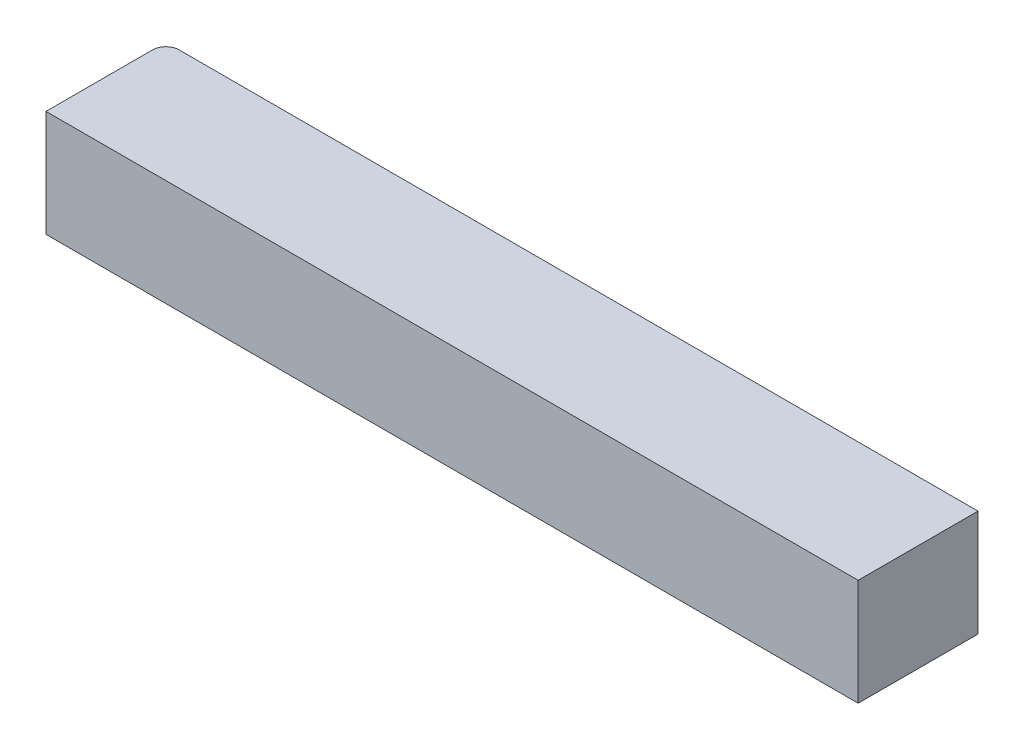
from build123d import *

# Parameters (mm, degrees)
BOSS_EXTRUDE1_DEPTH = 8


with BuildPart() as part:
    # Sketch1 → Boss-Extrude1 (new body)
    with BuildSketch(Plane(origin=(0, 0, 0), x_dir=(1, 0, 0), z_dir=(0, 1, 0))):
        with BuildLine():
            Line((-29.5, 4.5), (30.5, 4.5))
            Line((30.5, 4.5), (30.5, -4.5))
            Line((30.5, -4.5), (-30.5, -4.5))
            Line((-30.5, -4.5), (-30.5, 3.5))
            ThreePointArc((-30.5, 3.5), (-30.207106781, 4.207106781), (-29.5, 4.5))
        make_face()
    extrude(amount=BOSS_EXTRUDE1_DEPTH)


solid = part.part
